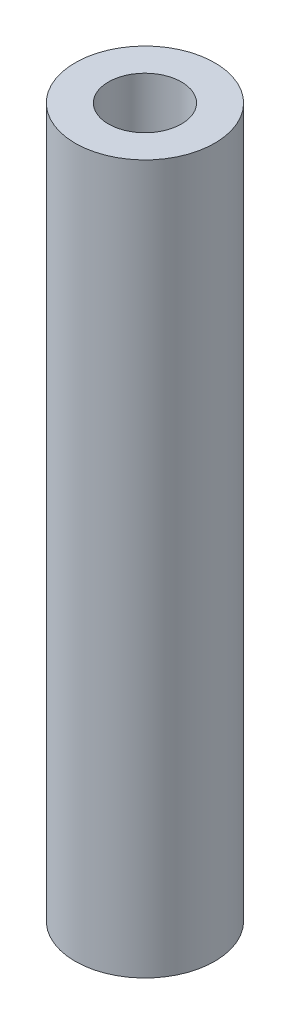
from build123d import *

# Parameters (mm, degrees)
SKETCH1_R           = 3.25
SKETCH1_R_2         = 1.7
BOSS_EXTRUDE1_DEPTH = 33


with BuildPart() as part:
    # Sketch1 → Boss-Extrude1 (new body)
    with BuildSketch(Plane(origin=(0, 0, 0), x_dir=(1, 0, 0), z_dir=(0, 1, 0))):
        Circle(SKETCH1_R)
        Circle(SKETCH1_R_2, mode=Mode.SUBTRACT)
    extrude(amount=BOSS_EXTRUDE1_DEPTH)


solid = part.part
